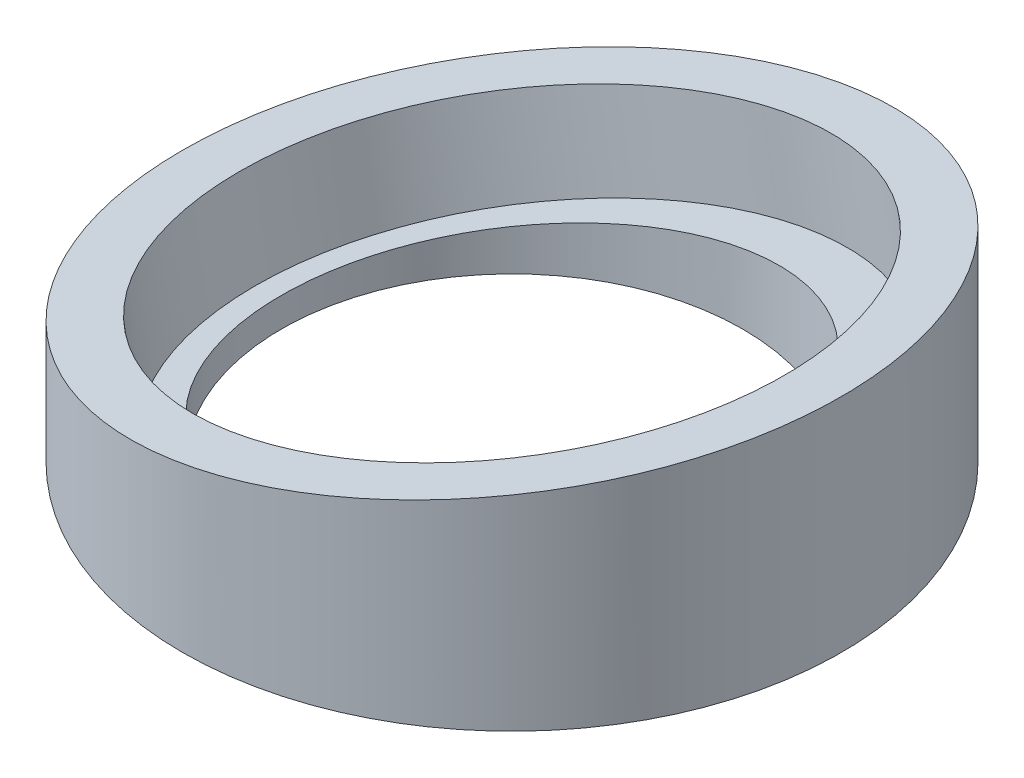
from build123d import *

# Parameters (mm, degrees)
SKETCH_1_R          = 25
EXTRUDE_1_DEPTH     = 20
SKETCH_2_R          = 17.5
CUT_EXTRUDE_1_DEPTH = 20
CUT_EXTRUDE_2_DEPTH = 38.5
SKETCH_4_R          = 21
CUT_EXTRUDE_3_DEPTH = 7


with BuildPart() as part:
    # 草图1 → 凸台-拉伸1 (new body)
    with BuildSketch(Plane(origin=(0, 0, 0), x_dir=(1, 0, 0), z_dir=(0, 1, 0))):
        Circle(SKETCH_1_R)
    extrude(amount=EXTRUDE_1_DEPTH)

    # 草图2 → 切除-拉伸1 (cut)
    with BuildSketch(Plane(origin=(0, 20, 0), x_dir=(1, 0, 0), z_dir=(0, 1, 0))):
        Circle(SKETCH_2_R)
    extrude(amount=-CUT_EXTRUDE_1_DEPTH, mode=Mode.SUBTRACT)

    # 草图3 → 切除-拉伸2 (cut, symmetric)
    with BuildSketch(Plane.XY):
        Polygon((-25, 8), (27.395295658, 17.238704287), (27.258418327, 39.934275436), (-34.828449814, 34.256390163), align=None)
    extrude(amount=CUT_EXTRUDE_2_DEPTH, both=True, mode=Mode.SUBTRACT)

    # 草图4 → 切除-拉伸3 (cut)
    with BuildSketch(Plane(origin=(-2.121922813, 12.034022275, 0), x_dir=(0.984807753, 0.173648178, 0), z_dir=(-0.173648178, 0.984807753, 0))):
        with Locations((2.154656893, 0)):
            Circle(SKETCH_4_R)
    extrude(amount=-CUT_EXTRUDE_3_DEPTH, mode=Mode.SUBTRACT)


solid = part.part
